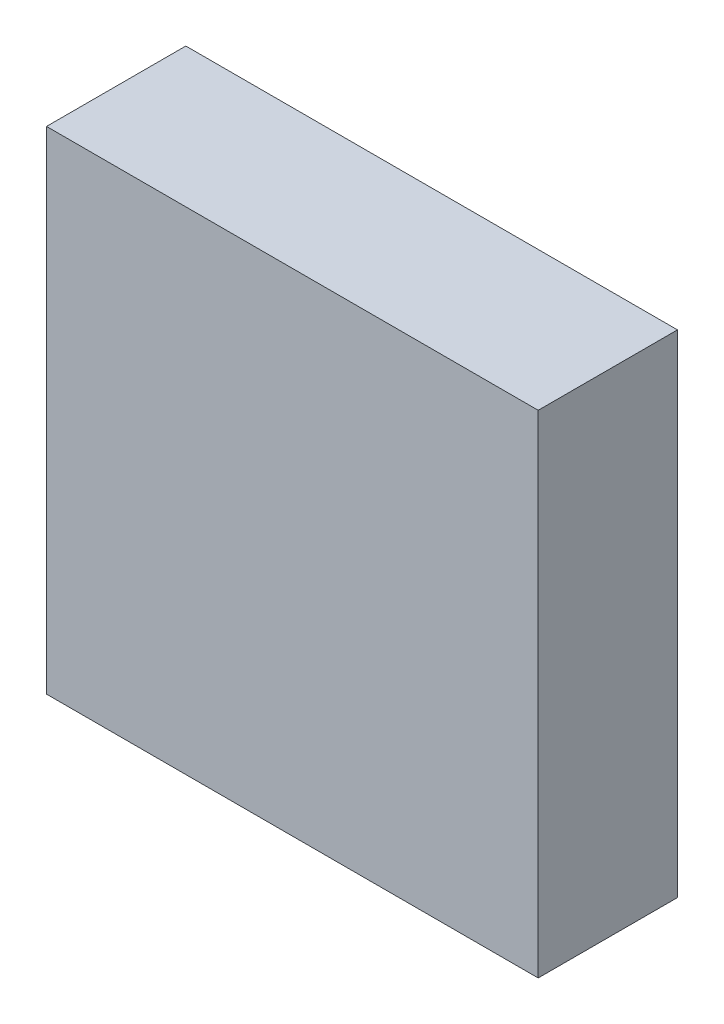
from build123d import *

# Parameters (mm, degrees)
SKETCH1_W           = 35.3
SKETCH1_H           = 35.3
BOSS_EXTRUDE1_DEPTH = 10


with BuildPart() as part:
    # Sketch1 → Boss-Extrude1 (new body)
    with BuildSketch(Plane.XY):
        Rectangle(SKETCH1_W, SKETCH1_H)
    extrude(amount=BOSS_EXTRUDE1_DEPTH)


solid = part.part
